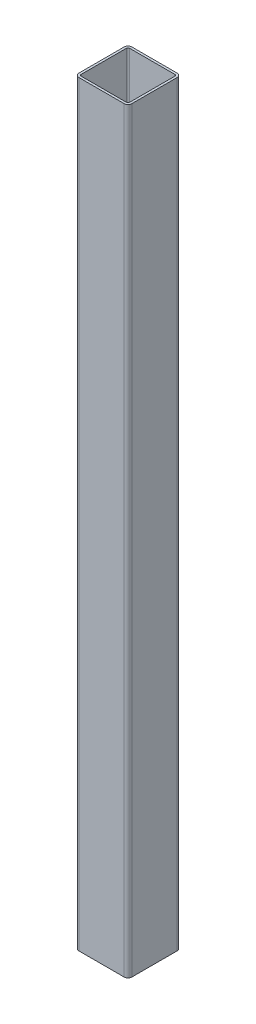
from build123d import *

# Parameters (mm, degrees)
EXTRUDE_1_DEPTH = 1000


with BuildPart() as part:
    # Эскиз1 → Вытянуть-Тонкостенный1 (new body)
    with BuildSketch(Plane(origin=(0, 0, 0), x_dir=(1, 0, 0), z_dir=(0, 1, 0))):
        with BuildLine():
            Line((-35, -30), (-35, 30))
            ThreePointArc((-35, 30), (-33.535533906, 33.535533906), (-30, 35))
            Line((-30, 35), (30, 35))
            ThreePointArc((30, 35), (33.535533906, 33.535533906), (35, 30))
            Line((35, 30), (35, -30))
            ThreePointArc((35, -30), (33.535533906, -33.535533906), (30, -35))
            Line((30, -35), (-30, -35))
            ThreePointArc((-30, -35), (-33.535533906, -33.535533906), (-35, -30))
        make_face()
        with BuildLine():
            Line((-32, -30), (-32, 30))
            ThreePointArc((-32, 30), (-31.414213562, 31.414213562), (-30, 32))
            Line((-30, 32), (30, 32))
            ThreePointArc((30, 32), (31.414213562, 31.414213562), (32, 30))
            Line((32, 30), (32, -30))
            ThreePointArc((32, -30), (31.414213562, -31.414213562), (30, -32))
            Line((30, -32), (-30, -32))
            ThreePointArc((-30, -32), (-31.414213562, -31.414213562), (-32, -30))
        make_face(mode=Mode.SUBTRACT)
    extrude(amount=EXTRUDE_1_DEPTH)


solid = part.part
